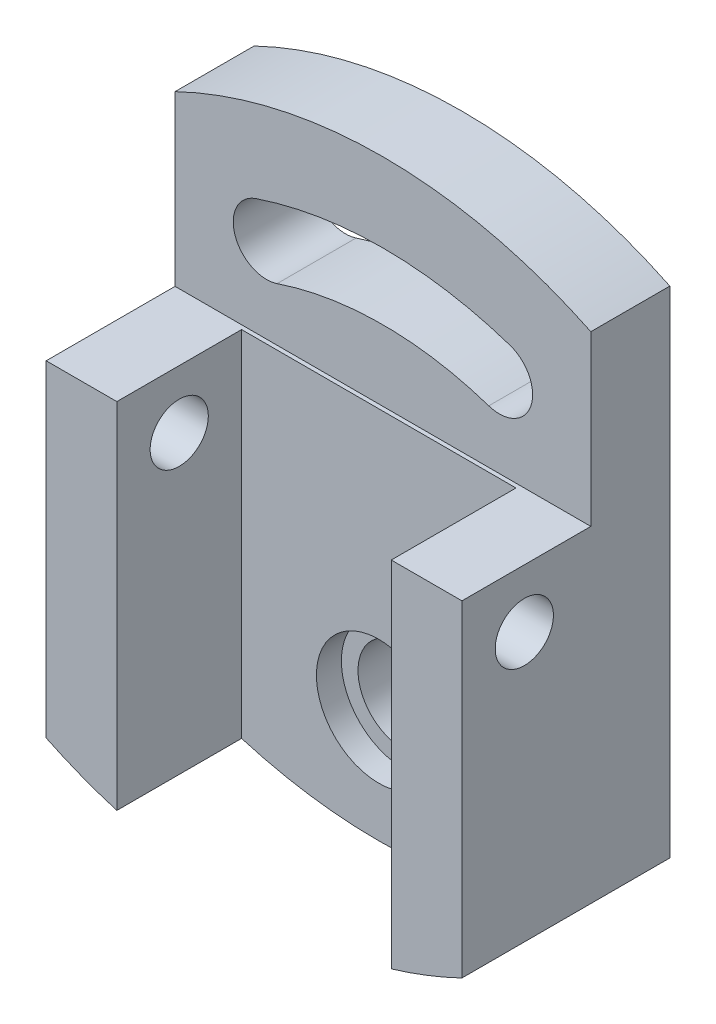
from build123d import *

# Parameters (mm, degrees)
BOSS_EXTRUDE1_DEPTH = 20
BOSS_EXTRUDE2_DEPTH = 30
CUT_EXTRUDE1_DEPTH  = 1
SKETCH8_R           = 15
CUT_EXTRUDE2_DEPTH  = 6
SKETCH9_R           = 11
CUT_EXTRUDE3_DEPTH  = 15
SKETCH10_R          = 7
CUT_EXTRUDE4_DEPTH  = 101


with BuildPart() as part:
    # Sketch3 → Boss-Extrude1 (new body)
    with BuildSketch(Plane.XY):
        with BuildLine():
            Line((-50, 103.561575886), (-50, -15.561575886))
            ThreePointArc((-50, -15.561575886), (0, -27), (50, -15.561575886))
            Line((50, -15.561575886), (50, 103.561575886))
            ThreePointArc((50, 103.561575886), (0, 115), (-50, 103.561575886))
        make_face()
        with BuildLine():
            ThreePointArc((30.545454545, 91.010852136), (0, 96), (-30.545454545, 91.010852136))
            ThreePointArc((-30.545454545, 91.010852136), (-35.584237678, 80.881159913), (-25.454545455, 75.84237678))
            ThreePointArc((-25.454545455, 75.84237678), (0, 80), (25.454545455, 75.84237678))
            ThreePointArc((25.454545455, 75.84237678), (35.584237678, 80.881159913), (30.545454545, 91.010852136))
        make_face(mode=Mode.SUBTRACT)
    extrude(amount=BOSS_EXTRUDE1_DEPTH)

    # Sketch5 → Boss-Extrude2 (add)
    with BuildSketch(Plane.XY.offset(20)):
        with BuildLine():
            Line((-50, 63), (-33, 63))
            Line((-33, 63), (-33, -22.163514831))
            ThreePointArc((-33, -22.163514831), (-41.631074926, -19.200063435), (-50, -15.561575886))
            Line((-50, -15.561575886), (-50, 63))
        make_face()
        with BuildLine():
            Line((50, -15.561575886), (50, 63))
            Line((50, 63), (33, 63))
            Line((33, 63), (33, -22.163514831))
            ThreePointArc((33, -22.163514831), (41.631074926, -19.200063435), (50, -15.561575886))
        make_face()
    extrude(amount=BOSS_EXTRUDE2_DEPTH)

    # Sketch6 → Cut-Extrude1 (cut)
    with BuildSketch(Plane.XY.offset(20)):
        with BuildLine():
            Line((-33, 63), (33, 63))
            Line((33, 63), (50, 63))
            Line((50, 63), (50, 103.561575886))
            ThreePointArc((50, 103.561575886), (0, 115), (-50, 103.561575886))
            Line((-50, 103.561575886), (-50, 63))
            Line((-50, 63), (-33, 63))
        make_face()
    extrude(amount=-CUT_EXTRUDE1_DEPTH, mode=Mode.SUBTRACT)

    # Sketch8 → Cut-Extrude2 (cut)
    with BuildSketch(Plane.XY.offset(20)):
        Circle(SKETCH8_R)
    extrude(amount=-CUT_EXTRUDE2_DEPTH, mode=Mode.SUBTRACT)

    # Sketch9 → Cut-Extrude3 (cut, through all)
    with BuildSketch(Plane.XY.offset(14)):
        Circle(SKETCH9_R)
    extrude(amount=-CUT_EXTRUDE3_DEPTH, mode=Mode.SUBTRACT)

    # Sketch10 → Cut-Extrude4 (cut, through all)
    with BuildSketch(Plane(origin=(50, 0, 0), x_dir=(0, 0, -1), z_dir=(1, 0, 0))):
        with Locations((-35, 49)):
            Circle(SKETCH10_R)
    extrude(amount=-CUT_EXTRUDE4_DEPTH, mode=Mode.SUBTRACT)


solid = part.part
